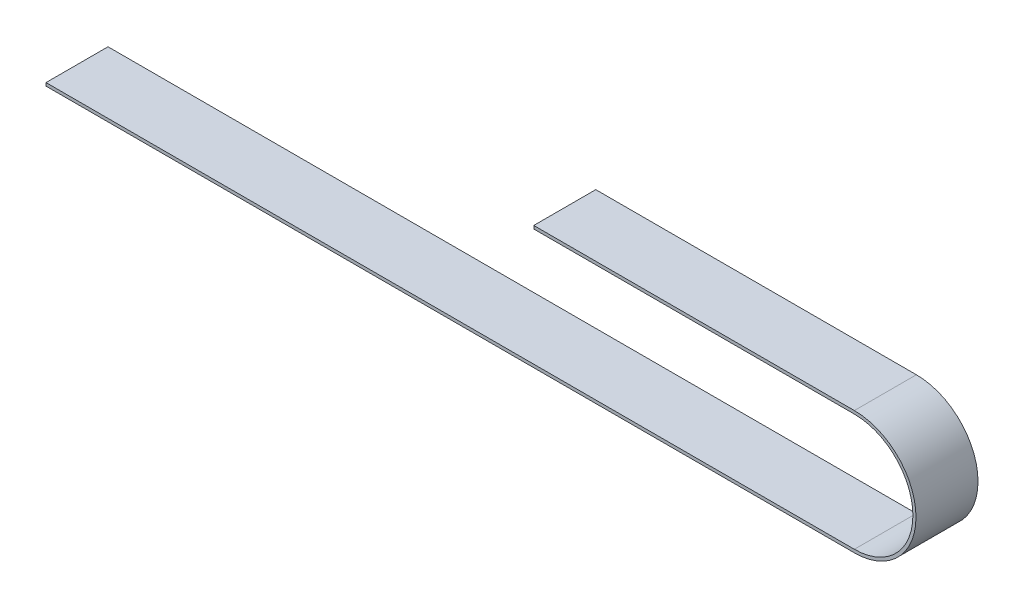
from build123d import *

# Parameters (mm, degrees)
EXTRUDE_THIN1_START = -5
EXTRUDE_THIN1_DEPTH = 40


with BuildPart() as part:
    # Sketch1 → Extrude-Thin1 (new body)
    with BuildSketch(Plane.XY.offset(EXTRUDE_THIN1_START)):
        with BuildLine():
            Line((0, 54), (521.447237603, 54))
            ThreePointArc((521.447237603, 54), (561.197237603, 93.75), (521.447237603, 133.5))
            Line((521.447237603, 133.5), (314.631190532, 133.5))
            Line((314.631190532, 133.5), (314.631190532, 131.5))
            Line((314.631190532, 131.5), (521.447237603, 131.5))
            ThreePointArc((521.447237603, 131.5), (559.197237603, 93.75), (521.447237603, 56))
            Line((521.447237603, 56), (0, 56))
            Line((0, 56), (0, 54))
        make_face()
    extrude(amount=-EXTRUDE_THIN1_DEPTH)


solid = part.part
